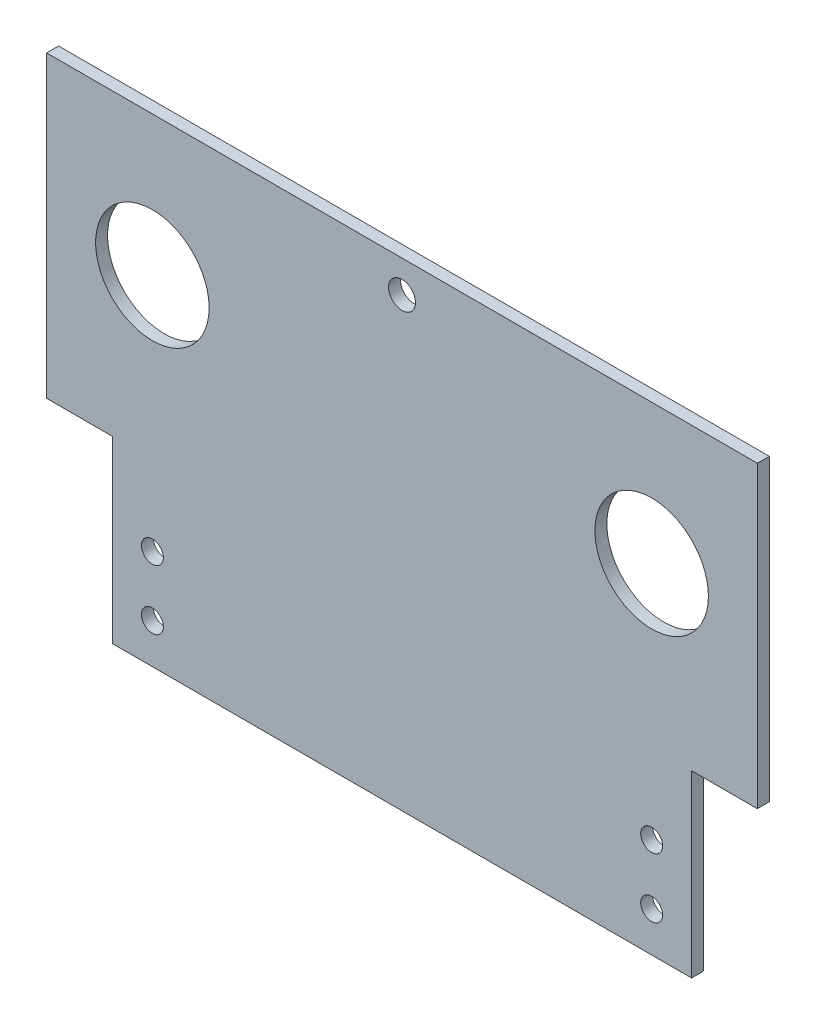
from build123d import *

# Parameters (mm, degrees)
SKETCH1_W           = 178.16
SKETCH1_H           = 120
BOSS_EXTRUDE1_DEPTH = 3
SKETCH2_R           = 14.225
SKETCH2_R_2         = 2.75
SKETCH2_R_3         = 3.375
CUT_EXTRUDE1_DEPTH  = 4
SKETCH3_W           = 16.5
SKETCH3_H           = 45
CUT_EXTRUDE2_DEPTH  = 4


with BuildPart() as part:
    # Sketch1 → Boss-Extrude1 (new body)
    with BuildSketch(Plane.XY):
        with Locations((89.08, -60)):
            Rectangle(SKETCH1_W, SKETCH1_H)
    extrude(amount=BOSS_EXTRUDE1_DEPTH)

    # Sketch2 → Cut-Extrude1 (cut, through all)
    with BuildSketch(Plane.XY.offset(3)):
        with Locations((26.5, -35)):
            Circle(SKETCH2_R)
        with Locations((151.66, -35)):
            Circle(SKETCH2_R)
        with Locations((26.5, -110)):
            Circle(SKETCH2_R_2)
        with Locations((151.66, -110)):
            Circle(SKETCH2_R_2)
        with Locations((89.08, -8)):
            Circle(SKETCH2_R_3)
        with Locations((26.5, -95)):
            Circle(SKETCH2_R_2)
        with Locations((151.66, -95)):
            Circle(SKETCH2_R_2)
    extrude(amount=-CUT_EXTRUDE1_DEPTH, mode=Mode.SUBTRACT)

    # Sketch3 → Cut-Extrude2 (cut, through all)
    with BuildSketch(Plane(origin=(0, 0, 0), x_dir=(-1, 0, 0), z_dir=(0, 0, -1))):
        with Locations((-8.25, -97.5)):
            Rectangle(SKETCH3_W, SKETCH3_H)
        with Locations((-169.91, -97.5)):
            Rectangle(SKETCH3_W, SKETCH3_H)
    extrude(amount=-CUT_EXTRUDE2_DEPTH, mode=Mode.SUBTRACT)


solid = part.part
